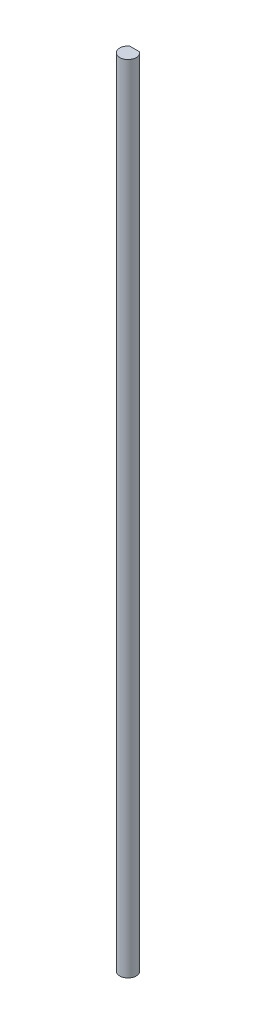
from build123d import *

# Parameters (mm, degrees)
BOSS_EXTRUDE1_DEPTH = 304.8


with BuildPart() as part:
    # Sketch1 → Boss-Extrude1 (new body)
    with BuildSketch(Plane(origin=(0, 0, 0), x_dir=(1, 0, 0), z_dir=(0, 1, 0))):
        with BuildLine():
            Line((-1.905, 2.54), (1.905, 2.54))
            ThreePointArc((1.905, 2.54), (0, -3.175), (-1.905, 2.54))
        make_face()
    extrude(amount=BOSS_EXTRUDE1_DEPTH)


solid = part.part
